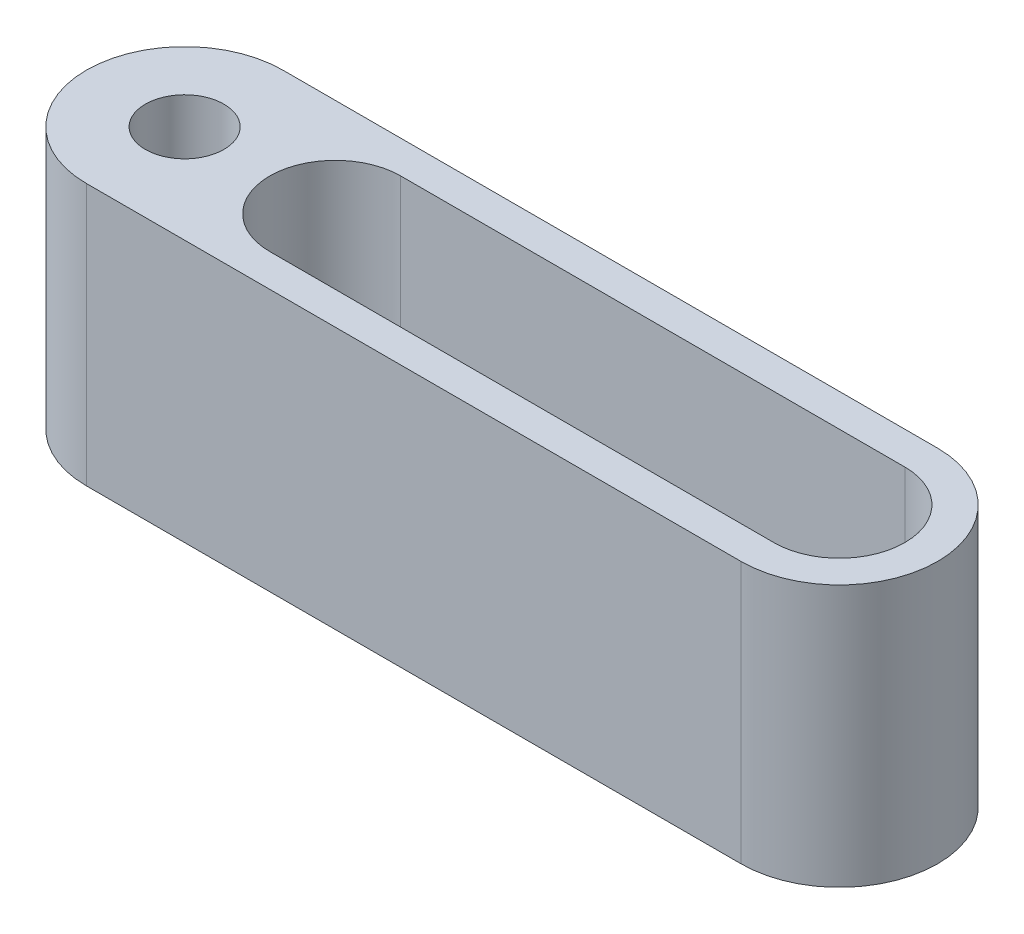
from build123d import *

# Parameters (mm, degrees)
SKETCH1_R           = 6
BOSS_EXTRUDE1_DEPTH = 40
SKETCH1_2_R         = 6
BOSS_EXTRUDE2_DEPTH = 4


with BuildPart() as part:
    # Sketch1 → Boss-Extrude1 (new body)
    with BuildSketch(Plane(origin=(0, 0, 0), x_dir=(1, 0, 0), z_dir=(0, 1, 0))):
        with BuildLine():
            Line((0, -15), (100, -15))
            ThreePointArc((100, -15), (115, 0), (100, 15))
            Line((100, 15), (0, 15))
            ThreePointArc((0, 15), (-15, 0), (0, -15))
        make_face()
        Circle(SKETCH1_R, mode=Mode.SUBTRACT)
        with BuildLine():
            Line((23, 10), (100, 10))
            ThreePointArc((100, 10), (110, 0), (100, -10))
            Line((100, -10), (23, -10))
            ThreePointArc((23, -10), (13, 0), (23, 10))
        make_face(mode=Mode.SUBTRACT)
    extrude(amount=BOSS_EXTRUDE1_DEPTH)

    # Sketch1_2 → Boss-Extrude2 (add)
    with BuildSketch(Plane(origin=(0, 0, 0), x_dir=(1, 0, 0), z_dir=(0, 1, 0))):
        with BuildLine():
            Line((100, 10), (23, 10))
            ThreePointArc((23, 10), (13, 0), (23, -10))
            Line((23, -10), (100, -10))
            ThreePointArc((100, -10), (110, 0), (100, 10))
        make_face()
        Circle(SKETCH1_2_R)
    extrude(amount=BOSS_EXTRUDE2_DEPTH)


solid = part.part
